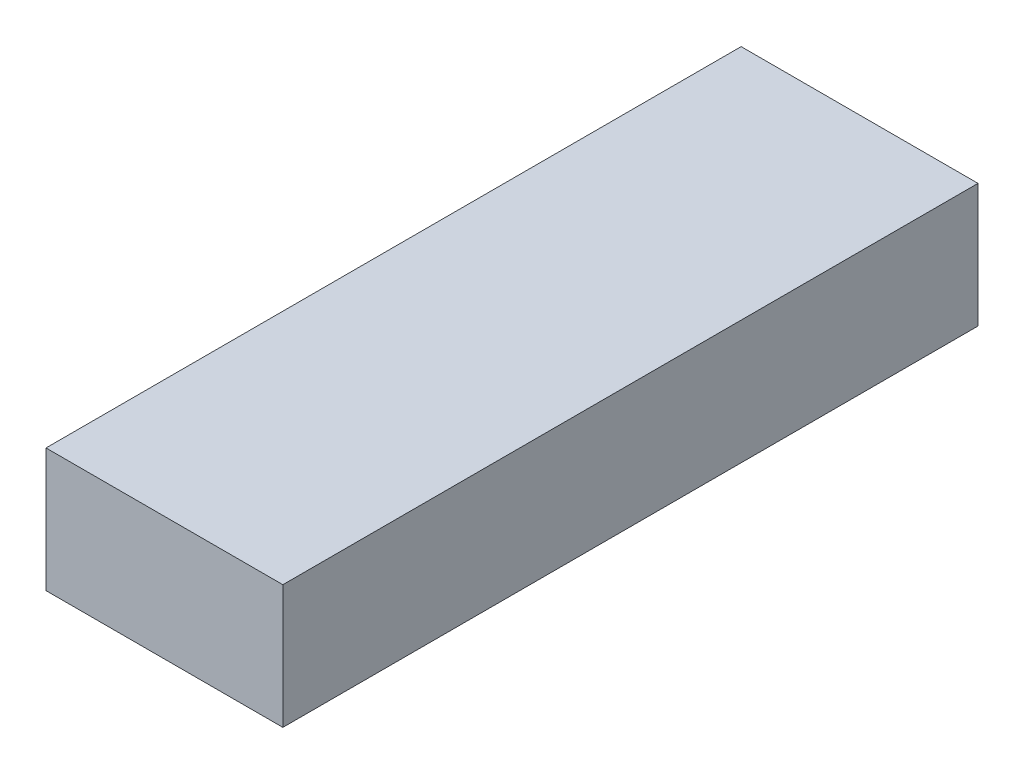
from build123d import *

# Parameters (mm, degrees)
SKETCH1_W           = 46
SKETCH1_H           = 135
BOSS_EXTRUDE1_DEPTH = 24


with BuildPart() as part:
    # Sketch1 → Boss-Extrude1 (new body)
    with BuildSketch(Plane(origin=(0, 0, 0), x_dir=(1, 0, 0), z_dir=(0, 1, 0))):
        with Locations((23, 67.5)):
            Rectangle(SKETCH1_W, SKETCH1_H)
    extrude(amount=BOSS_EXTRUDE1_DEPTH)


solid = part.part
